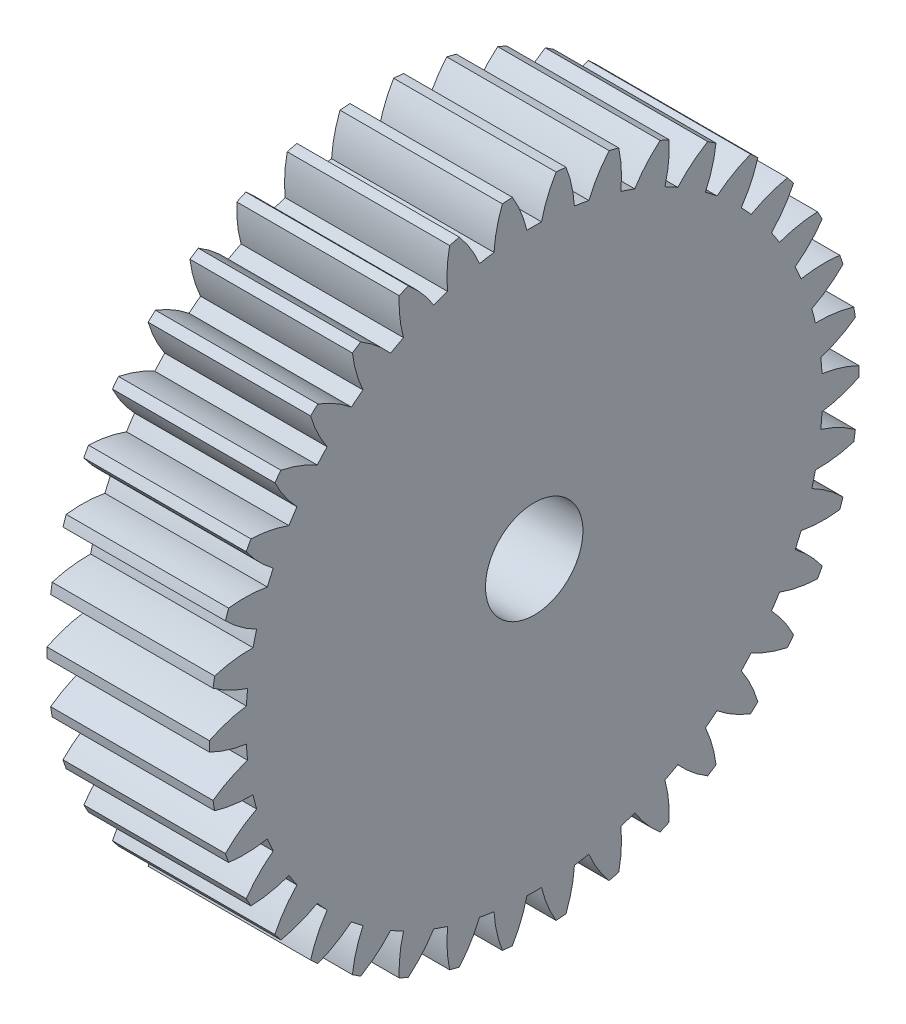
from build123d import *

# Parameters (mm, degrees)
BASPROSKE_W     = 10
BASPROSKE_H     = 20
TOOTHCUT_DEPTH  = 31
TEETHCUTS_COUNT = 38
TEETHCUTS_ANGLE = 350.526315789
BORSKE_R        = 3
BORE_DEPTH      = 50.0000508


with BuildPart() as part:
    # BasProSke → Base-Revolve (revolve)
    with BuildSketch(Plane(origin=(0, 0, 0), x_dir=(1, 0, 0), z_dir=(0, 1, 0)), mode=Mode.PRIVATE) as base_revolve_sk:
        with Locations((5, 10)):
            Rectangle(BASPROSKE_W, BASPROSKE_H)
    revolve(base_revolve_sk.sketch.rotate(Axis((-10, 0, 0), (1, 0, 0)), 180), axis=Axis((-10, 0, 0), (1, 0, 0)))

    # TooCutSke → ToothCut (cut, through all)
    with BuildSketch(Plane(origin=(0, 0, 0), x_dir=(0, 0, -1), z_dir=(1, 0, 0))):
        with BuildLine():
            ThreePointArc((0.451522093, 17.743255868), (0, 17.749), (-0.451522093, 17.743255868))
            ThreePointArc((-0.451522093, 17.743255868), (-0.817150678, 18.897517772), (-1.361445068, 19.979066857))
            ThreePointArc((-1.361445068, 19.979066857), (0, 20.0254), (1.361445068, 19.979066857))
            ThreePointArc((1.361445068, 19.979066857), (0.817150678, 18.897517772), (0.451522093, 17.743255868))
        make_face()
    toothcut = extrude(amount=TOOTHCUT_DEPTH, mode=Mode.SUBTRACT)

    # TeethCuts: ToothCut ×38 about axis
    teethcuts_axis = Axis((-10, 0, 0), (1, 0, 0))
    for i in range(1, TEETHCUTS_COUNT):
        add(toothcut.rotate(teethcuts_axis, i * TEETHCUTS_ANGLE / (TEETHCUTS_COUNT - 1)), mode=Mode.SUBTRACT)

    # BorSke → Bore (cut, symmetric)
    with BuildSketch(Plane(origin=(0, 0, 0), x_dir=(0, 0, -1), z_dir=(1, 0, 0))):
        with Locations(Location((0, 0, 0), (0, 0, 180))):
            Circle(BORSKE_R)
    extrude(amount=BORE_DEPTH, both=True, mode=Mode.SUBTRACT)


solid = part.part
